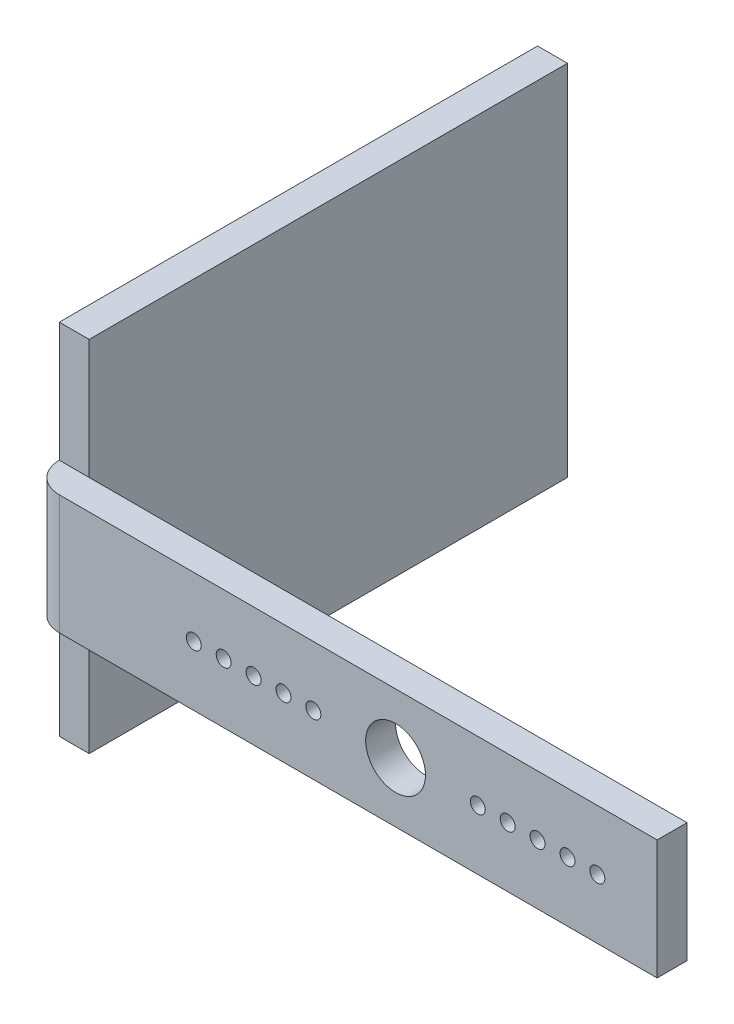
from build123d import *

# Parameters (mm, degrees)
SKETCH1_W           = 63.5
SKETCH1_H           = 12.7
BOSS_EXTRUDE1_DEPTH = 3.175
SKETCH2_W           = 50.8
SKETCH2_H           = 38.1
BOSS_EXTRUDE2_DEPTH = 3.175
BOSS_EXTRUDE3_DEPTH = 12.7
SKETCH3_R           = 0.79375
CUT_EXTRUDE1_DEPTH  = 6.35
LPATTERN1_COUNT     = 5
LPATTERN1_PITCH     = 3.175
SKETCH5_R           = 0.79375
CUT_EXTRUDE2_DEPTH  = 6.35
LPATTERN2_COUNT     = 5
LPATTERN2_PITCH     = 3.175
SKETCH6_R           = 3.175
CUT_EXTRUDE3_DEPTH  = 54.975


with BuildPart() as part:
    # Sketch1 → Boss-Extrude1 (new body)
    with BuildSketch(Plane.XY):
        Rectangle(SKETCH1_W, SKETCH1_H)
    extrude(amount=BOSS_EXTRUDE1_DEPTH)



with BuildPart() as body_2:
    # Sketch2 → Boss-Extrude2 (new body)
    with BuildSketch(Plane.ZY.offset(31.75)):
        with Locations((-25.4, 0)):
            Rectangle(SKETCH2_W, SKETCH2_H)
    extrude(amount=BOSS_EXTRUDE2_DEPTH)


with BuildPart() as part_1:
    add(part.part)

    add(body_2.part)  # Boss-Extrude3 merges body 2
    # Sketch4 → Boss-Extrude3 (add)
    with BuildSketch(Plane(origin=(0, 6.35, 0), x_dir=(1, 0, 0), z_dir=(0, 1, 0))):
        with BuildLine():
            Line((-34.925, 0), (-31.75, 0))
            Line((-31.75, 0), (-31.75, -3.175))
            ThreePointArc((-31.75, -3.175), (-33.99506403, -2.24506403), (-34.925, 0))
        make_face()
    extrude(amount=-BOSS_EXTRUDE3_DEPTH)

    # Sketch3 → Cut-Extrude1 (cut)
    with BuildSketch(Plane.XY.offset(3.175)):
        with Locations((25.4, 0)):
            Circle(SKETCH3_R)
    cut_extrude1 = extrude(amount=-CUT_EXTRUDE1_DEPTH, mode=Mode.SUBTRACT)

    # LPattern1: Cut-Extrude1 ×5
    with Locations(*[(-i * LPATTERN1_PITCH, 0, 0) for i in range(1, LPATTERN1_COUNT)]):
        add(cut_extrude1, mode=Mode.SUBTRACT)

    # Sketch5 → Cut-Extrude2 (cut)
    with BuildSketch(Plane.XY.offset(3.175)):
        with Locations((-4.7625, 0)):
            Circle(SKETCH5_R)
    cut_extrude2 = extrude(amount=-CUT_EXTRUDE2_DEPTH, mode=Mode.SUBTRACT)

    # LPattern2: Cut-Extrude2 ×5
    with Locations(*[(-i * LPATTERN2_PITCH, 0, 0) for i in range(1, LPATTERN2_COUNT)]):
        add(cut_extrude2, mode=Mode.SUBTRACT)

    # Sketch6 → Cut-Extrude3 (cut, through all)
    with BuildSketch(Plane.XY.offset(3.175)):
        with Locations((3.96875, 0)):
            Circle(SKETCH6_R)
    extrude(amount=-CUT_EXTRUDE3_DEPTH, mode=Mode.SUBTRACT)


solid = part_1.part
